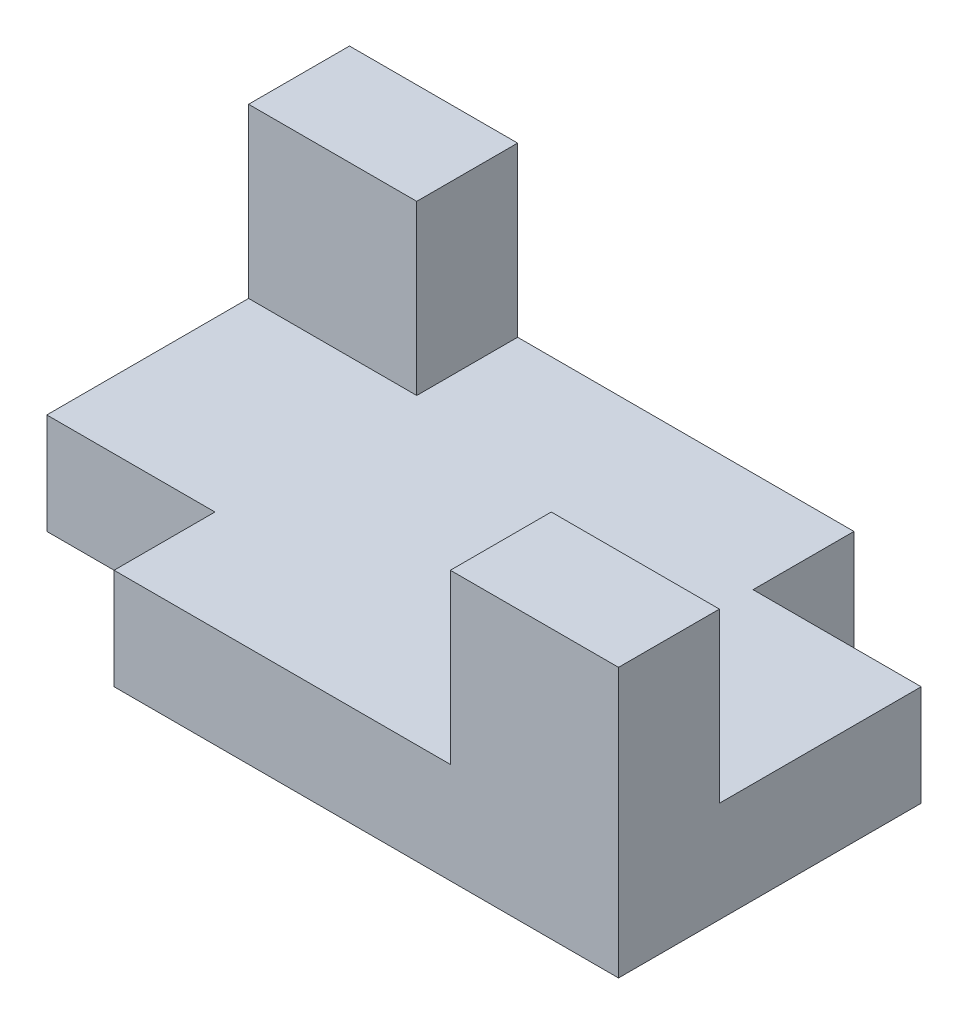
from build123d import *

# Parameters (mm, degrees)
SKETCH2_W           = 100
SKETCH2_H           = 60
BOSS_EXTRUDE1_DEPTH = 15
SKETCH3_W           = 25
SKETCH3_H           = 15
BOSS_EXTRUDE2_DEPTH = 25
SKETCH4_W           = 25
SKETCH4_H           = 15
BOSS_EXTRUDE3_DEPTH = 25
SKETCH5_W           = 25
SKETCH5_H           = 15
CUT_EXTRUDE1_DEPTH  = 15
SKETCH6_W           = 25
SKETCH6_H           = 15
CUT_EXTRUDE2_DEPTH  = 15


with BuildPart() as part:
    # Sketch2 → Boss-Extrude1 (new body)
    with BuildSketch(Plane(origin=(0, 0, 0), x_dir=(1, 0, 0), z_dir=(0, 1, 0))):
        with Locations((2.681325602, -1.373990244)):
            Rectangle(SKETCH2_W, SKETCH2_H)
    extrude(amount=BOSS_EXTRUDE1_DEPTH)

    # Sketch3 → Boss-Extrude2 (add)
    with BuildSketch(Plane(origin=(0, 15, 0), x_dir=(1, 0, 0), z_dir=(0, 1, 0))):
        with Locations((-34.818674398, 21.126009756)):
            Rectangle(SKETCH3_W, SKETCH3_H)
    extrude(amount=BOSS_EXTRUDE2_DEPTH)

    # Sketch4 → Boss-Extrude3 (add)
    with BuildSketch(Plane(origin=(0, 15, 0), x_dir=(1, 0, 0), z_dir=(0, 1, 0))):
        with Locations((40.181325602, -23.873990244)):
            Rectangle(SKETCH4_W, SKETCH4_H)
    extrude(amount=BOSS_EXTRUDE3_DEPTH)

    # Sketch5 → Cut-Extrude1 (cut)
    with BuildSketch(Plane(origin=(0, 15, 0), x_dir=(1, 0, 0), z_dir=(0, 1, 0))):
        with Locations((-34.818674398, -23.873990244)):
            Rectangle(SKETCH5_W, SKETCH5_H)
    extrude(amount=-CUT_EXTRUDE1_DEPTH, mode=Mode.SUBTRACT)

    # Sketch6 → Cut-Extrude2 (cut)
    with BuildSketch(Plane(origin=(0, 15, 0), x_dir=(1, 0, 0), z_dir=(0, 1, 0))):
        with Locations((40.181325602, 21.126009756)):
            Rectangle(SKETCH6_W, SKETCH6_H)
    extrude(amount=-CUT_EXTRUDE2_DEPTH, mode=Mode.SUBTRACT)


solid = part.part
